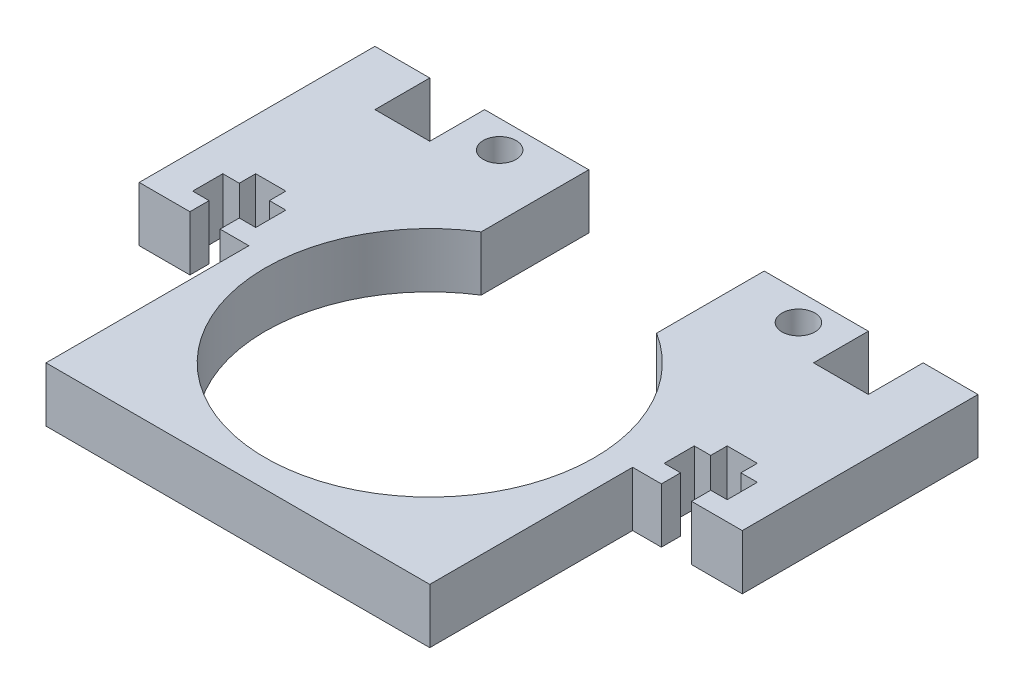
from build123d import *

# Parameters (mm, degrees)
ESQUISSE1_W             = 35
ESQUISSE1_H             = 35
BOSS_EXTRU_1_DEPTH      = 5
ESQUISSE3_R             = 15
ENL_V_MAT_EXTRU_1_DEPTH = 5
ESQUISSE5_W             = 10
ESQUISSE5_H             = 16.5
BOSS_EXTRU_3_DEPTH      = 5
ENL_V_MAT_EXTRU_3_DEPTH = 10
ESQUISSE2_W             = 55
ESQUISSE2_H             = 5
BOSS_EXTRU_4_DEPTH      = 5
ESQUISSE8_W             = 16
ESQUISSE8_H             = 9.81142246
ENL_V_MAT_EXTRU_5_DEPTH = 5
ESQUISSE9_W             = 5
ESQUISSE9_H             = 5
ENL_V_MAT_EXTRU_6_DEPTH = 5
ESQUISSE10_R            = 1.5
ENL_V_MAT_EXTRU_7_DEPTH = 6


with BuildPart() as part:
    # Esquisse1 → Boss.-Extru.1 (new body)
    with BuildSketch(Plane(origin=(0, 0, 0), x_dir=(1, 0, 0), z_dir=(0, 1, 0))):
        Rectangle(ESQUISSE1_W, ESQUISSE1_H)
    extrude(amount=BOSS_EXTRU_1_DEPTH)

    # Esquisse3 → Enlèv. mat.-Extru.1 (cut)
    with BuildSketch(Plane(origin=(0, 5, 0), x_dir=(1, 0, 0), z_dir=(0, 1, 0))):
        Circle(ESQUISSE3_R)
    extrude(amount=-ENL_V_MAT_EXTRU_1_DEPTH, mode=Mode.SUBTRACT)

    # Esquisse5 → Boss.-Extru.3 (add)
    with BuildSketch(Plane(origin=(0, 5, 0), x_dir=(1, 0, 0), z_dir=(0, 1, 0))):
        with Locations((-22.5, 9.25)):
            Rectangle(ESQUISSE5_W, ESQUISSE5_H)
    boss_extru_3 = extrude(amount=-BOSS_EXTRU_3_DEPTH)

    # Symétrie1: Boss.-Extru.3 across plane
    add(boss_extru_3.mirror(Plane(origin=(0, 0, 0), x_dir=(0, 0, 1), z_dir=(1, 0, 0))))

    # Esquisse7 → Enlèv. mat.-Extru.3 (cut)
    with BuildSketch(Plane(origin=(0, 5, 0), x_dir=(1, 0, 0), z_dir=(0, 1, 0))):
        Polygon((-22.875, 1), (-22.875, 2.75), (-24.375, 2.75), (-24.375, 5.5), (-22.875, 5.5), (-22.875, 7), (-20.125, 7), (-20.125, 5.5), (-18.625, 5.5), (-18.625, 2.75), (-20.125, 2.75), (-20.125, 1), align=None)
    enl_v_mat_extru_3 = extrude(amount=-ENL_V_MAT_EXTRU_3_DEPTH, mode=Mode.SUBTRACT)

    # Symétrie2: Enlèv. mat.-Extru.3 across plane
    add(enl_v_mat_extru_3.mirror(Plane(origin=(0, 0, 0), x_dir=(0, 0, 1), z_dir=(1, 0, 0))), mode=Mode.SUBTRACT)

    # Esquisse2 → Boss.-Extru.4 (add)
    with BuildSketch(Plane(origin=(0, 5, 0), x_dir=(1, 0, 0), z_dir=(0, 1, 0))):
        with Locations((0, 20)):
            Rectangle(ESQUISSE2_W, ESQUISSE2_H)
    extrude(amount=-BOSS_EXTRU_4_DEPTH)

    # Esquisse8 → Enlèv. mat.-Extru.5 (cut)
    with BuildSketch(Plane(origin=(0, 5, 0), x_dir=(1, 0, 0), z_dir=(0, 1, 0))):
        with Locations((0, 17.59428877)):
            Rectangle(ESQUISSE8_W, ESQUISSE8_H)
    extrude(amount=-ENL_V_MAT_EXTRU_5_DEPTH, mode=Mode.SUBTRACT)

    # Esquisse9 → Enlèv. mat.-Extru.6 (cut)
    with BuildSketch(Plane(origin=(0, 5, 0), x_dir=(1, 0, 0), z_dir=(0, 1, 0))):
        with Locations((-20, 20)):
            Rectangle(ESQUISSE9_W, ESQUISSE9_H)
        with Locations((20, 20)):
            Rectangle(ESQUISSE9_W, ESQUISSE9_H)
    extrude(amount=-ENL_V_MAT_EXTRU_6_DEPTH, mode=Mode.SUBTRACT)

    # Esquisse10 → Enlèv. mat.-Extru.7 (cut, through all)
    with BuildSketch(Plane(origin=(0, 5, 0), x_dir=(1, 0, 0), z_dir=(0, 1, 0))):
        with Locations((-13.625, 20)):
            Circle(ESQUISSE10_R)
        with Locations((13.625, 20)):
            Circle(ESQUISSE10_R)
    extrude(amount=-ENL_V_MAT_EXTRU_7_DEPTH, mode=Mode.SUBTRACT)


solid = part.part
